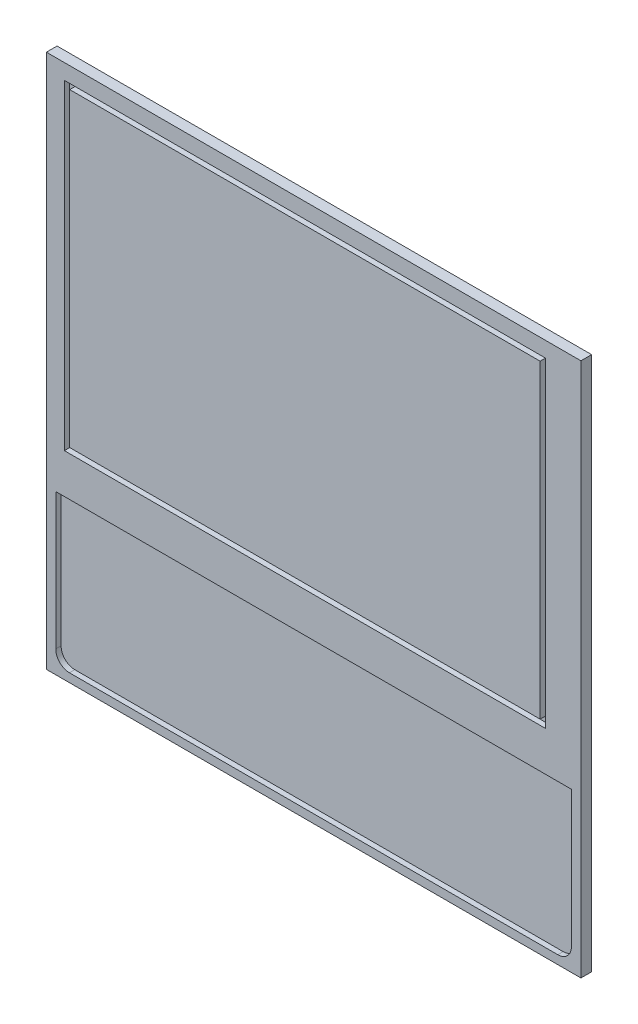
from build123d import *

# Parameters (mm, degrees)
SKETCH2_W           = 500
SKETCH2_H           = 500
BOSS_EXTRUDE1_DEPTH = 10
CUT_EXTRUDE1_DEPTH  = 5
SKETCH5_W           = 450
SKETCH5_H           = 300
SKETCH5_W_2         = 440
SKETCH5_H_2         = 290
CUT_EXTRUDE2_DEPTH  = 5


with BuildPart() as part:
    # Sketch2 → Boss-Extrude1 (new body)
    with BuildSketch(Plane.XY):
        Rectangle(SKETCH2_W, SKETCH2_H)
    extrude(amount=BOSS_EXTRUDE1_DEPTH)

    # Sketch4 → Cut-Extrude1 (cut)
    with BuildSketch(Plane.XY.offset(10)):
        with BuildLine():
            Line((241.065145693, -229.240987046), (241.219730906, -101.53377405))
            Line((241.219730906, -101.53377405), (-241.170400919, -101.53377405))
            Line((-241.170400919, -101.53377405), (-241.170400919, -228.946326042))
            ThreePointArc((-241.170400919, -228.946326042), (-237.553979354, -238.125325488), (-228.461270123, -241.953533239))
            Line((-228.461270123, -241.953533239), (228.3525995, -241.953533239))
            ThreePointArc((228.3525995, -241.953533239), (237.341727119, -238.230114666), (241.065145693, -229.240987046))
        make_face()
    extrude(amount=-CUT_EXTRUDE1_DEPTH, mode=Mode.SUBTRACT)

    # Sketch5 → Cut-Extrude2 (cut)
    with BuildSketch(Plane.XY.offset(10)):
        with Locations((-8.159820112, 85.603894722)):
            Rectangle(SKETCH5_W, SKETCH5_H)
        with Locations((-8.159820112, 85.603894722)):
            Rectangle(SKETCH5_W_2, SKETCH5_H_2, mode=Mode.SUBTRACT)
    extrude(amount=-CUT_EXTRUDE2_DEPTH, mode=Mode.SUBTRACT)


solid = part.part
